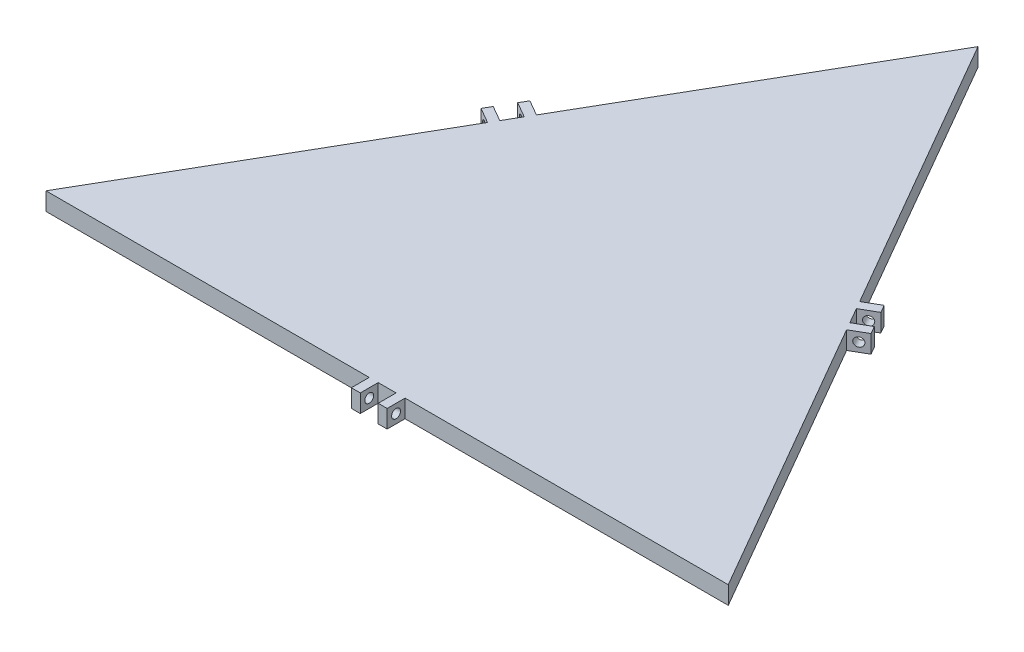
from build123d import *

# Parameters (mm, degrees)
BOSS_EXTRUDE1_DEPTH     = 10
SKETCH3_W               = 5
SKETCH3_H               = 10
BOSS_EXTRUDE2_DEPTH     = 10
SKETCH5_R               = 2.5
CUT_EXTRUDE1_DEPTH      = 20
MIRROR2_COPY_1_SKETCH_W = 5
MIRROR2_COPY_1_SKETCH_H = 10
MIRROR2_COPY_1_DEPTH    = 10
MIRROR2_COPY_2_SKETCH_R = 2.5
MIRROR2_COPY_2_DEPTH    = 20


with BuildPart() as part:
    # Sketch1 → Boss-Extrude1 (new body)
    with BuildSketch(Plane(origin=(0, 0, 0), x_dir=(1, 0, 0), z_dir=(0, 1, 0))):
        Polygon((-381.1, 0), (-190.55, 330.042281382), (0, 0), align=None)
    extrude(amount=BOSS_EXTRUDE1_DEPTH)

    # Sketch3 → Boss-Extrude2 (add)
    with BuildSketch(Plane(origin=(0, 0, 0), x_dir=(-0.5, 0, -0.866025404), z_dir=(0.866025404, 0, -0.5))):
        with Locations((198.05, 5)):
            Rectangle(SKETCH3_W, SKETCH3_H)
        with Locations((183.05, 5)):
            Rectangle(SKETCH3_W, SKETCH3_H)
    boss_extrude2 = extrude(amount=BOSS_EXTRUDE2_DEPTH)

    # Sketch5 → Cut-Extrude1 (cut)
    with BuildSketch(Plane(origin=(-90.275, 0, -156.360886653), x_dir=(0.866025404, 0, -0.5), z_dir=(0.5, 0, 0.866025404))):
        with Locations((5, 5)):
            Circle(SKETCH5_R)
    cut_extrude1 = extrude(amount=-CUT_EXTRUDE1_DEPTH, mode=Mode.SUBTRACT)

    # Mirror1: Boss-Extrude2, Cut-Extrude1 across plane
    add(boss_extrude2.mirror(Plane(origin=(0, 0, 0), x_dir=(0.866025404, 0, 0.5), z_dir=(-0.5, 0, 0.866025404))))
    add(cut_extrude1.mirror(Plane(origin=(0, 0, 0), x_dir=(0.866025404, 0, 0.5), z_dir=(-0.5, 0, 0.866025404))), mode=Mode.SUBTRACT)

    # Mirror2: Boss-Extrude2, Cut-Extrude1 across plane
    add(boss_extrude2.mirror(Plane(origin=(-190.55, 0, 0), x_dir=(0, 0, 1), z_dir=(1, 0, 0))))
    add(cut_extrude1.mirror(Plane(origin=(-190.55, 0, 0), x_dir=(0, 0, 1), z_dir=(1, 0, 0))), mode=Mode.SUBTRACT)

    # Mirror2 copy 1 sketch → Mirror2 copy 1 (add)
    with BuildSketch(Plane(origin=(-381.1, 0, 0), x_dir=(1, 0, 0), z_dir=(0, 0, 1))):
        with Locations((198.05, 5)):
            Rectangle(MIRROR2_COPY_1_SKETCH_W, MIRROR2_COPY_1_SKETCH_H)
        with Locations((183.05, 5)):
            Rectangle(MIRROR2_COPY_1_SKETCH_W, MIRROR2_COPY_1_SKETCH_H)
    extrude(amount=MIRROR2_COPY_1_DEPTH)

    # Mirror2 copy 2 sketch → Mirror2 copy 2 (cut)
    with BuildSketch(Plane.ZY.offset(200.55)):
        with Locations((5, 5)):
            Circle(MIRROR2_COPY_2_SKETCH_R)
    extrude(amount=-MIRROR2_COPY_2_DEPTH, mode=Mode.SUBTRACT)


solid = part.part
